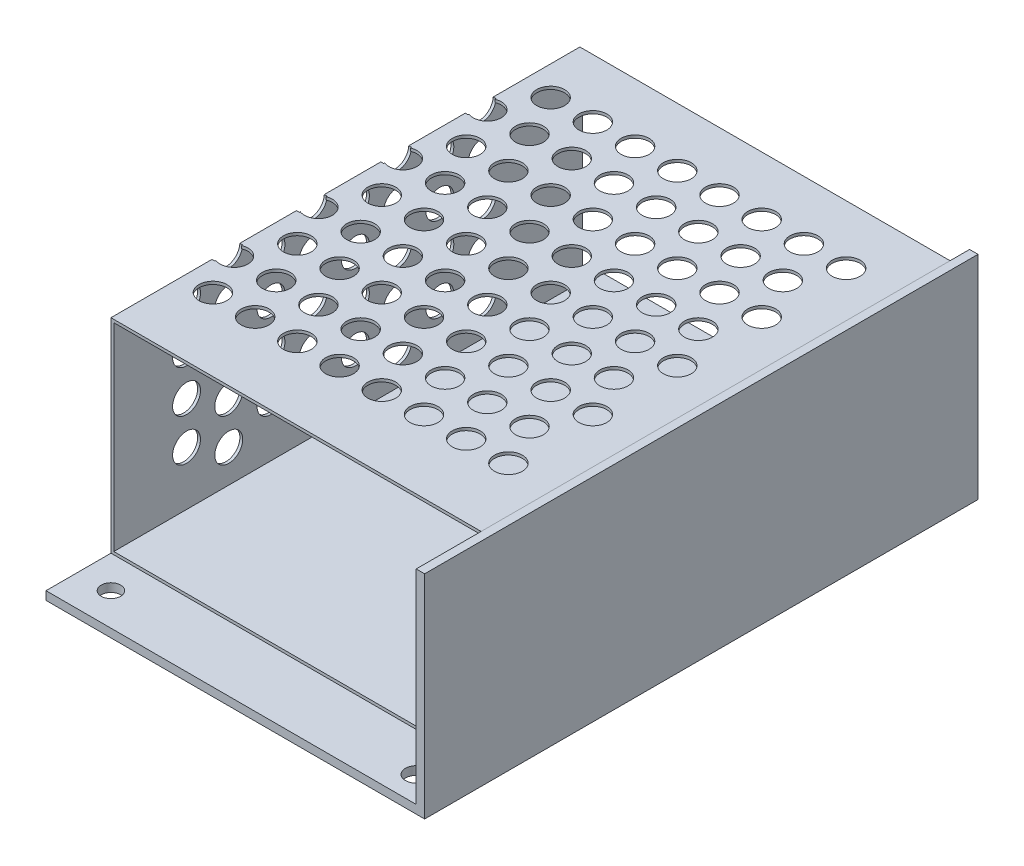
from build123d import *

# Parameters (mm, degrees)
SKETCH1_W           = 58.3
SKETCH1_H           = 85.2
BOSS_EXTRUDE1_DEPTH = 1.3
SKETCH2_W           = 1.3
SKETCH2_H           = 85.2
BOSS_EXTRUDE2_DEPTH = 31.4
CUT_EXTRUDE1_REACH  = 3.3
SKETCH3_R           = 1.5
SKETCH3_R_2         = 1.65
SKETCH4_W           = 57
SKETCH4_H           = 72.2
BOSS_EXTRUDE3_DEPTH = 31.4
SHELL1_T            = -0.44
SKETCH5_R           = 2.15
CUT_EXTRUDE2_DEPTH  = 0.44
SKETCH6_R           = 2.15
CUT_EXTRUDE3_DEPTH  = 0.44


with BuildPart() as part:
    # Sketch1 → Boss-Extrude1 (new body)
    with BuildSketch(Plane(origin=(0, 0, 0), x_dir=(1, 0, 0), z_dir=(0, 1, 0))):
        Rectangle(SKETCH1_W, SKETCH1_H)
    extrude(amount=BOSS_EXTRUDE1_DEPTH)

    # Sketch2 → Boss-Extrude2 (add)
    with BuildSketch(Plane(origin=(0, 1.3, 0), x_dir=(1, 0, 0), z_dir=(0, 1, 0))):
        with Locations((28.5, 0)):
            Rectangle(SKETCH2_W, SKETCH2_H)
    extrude(amount=BOSS_EXTRUDE2_DEPTH)

    # Sketch3 → Cut-Extrude1 (cut, up to next)
    with BuildSketch(Plane(origin=(0, 1.3, 0), x_dir=(1, 0, 0), z_dir=(0, 1, 0)), mode=Mode.PRIVATE) as cut_extrude1_sk1:
        with Locations((-24.15, -37.6)):
            Circle(SKETCH3_R)
    cut_extrude1_tool1 = extrude(cut_extrude1_sk1.sketch, amount=-CUT_EXTRUDE1_REACH, mode=Mode.PRIVATE) & part.part
    add(cut_extrude1_tool1.solids().sort_by_distance((-24.15, 1.3, 37.6))[0], mode=Mode.SUBTRACT)
    # Sketch3 → Cut-Extrude1 (cut, up to next)
    with BuildSketch(Plane(origin=(0, 1.3, 0), x_dir=(1, 0, 0), z_dir=(0, 1, 0)), mode=Mode.PRIVATE) as cut_extrude1_sk2:
        with Locations((-24.15, 29.4)):
            Circle(SKETCH3_R)
    cut_extrude1_tool2 = extrude(cut_extrude1_sk2.sketch, amount=-CUT_EXTRUDE1_REACH, mode=Mode.PRIVATE) & part.part
    add(cut_extrude1_tool2.solids().sort_by_distance((-24.15, 1.3, -29.4))[0], mode=Mode.SUBTRACT)
    # Sketch3 → Cut-Extrude1 (cut, up to next)
    with BuildSketch(Plane(origin=(0, 1.3, 0), x_dir=(1, 0, 0), z_dir=(0, 1, 0)), mode=Mode.PRIVATE) as cut_extrude1_sk3:
        with Locations((23.85, -38.6)):
            Circle(SKETCH3_R_2)
    cut_extrude1_tool3 = extrude(cut_extrude1_sk3.sketch, amount=-CUT_EXTRUDE1_REACH, mode=Mode.PRIVATE) & part.part
    add(cut_extrude1_tool3.solids().sort_by_distance((23.85, 1.3, 38.6))[0], mode=Mode.SUBTRACT)


with BuildPart() as body_2:
    # Sketch4 → Boss-Extrude3 (new body)
    with BuildSketch(Plane(origin=(0, 1.3, 0), x_dir=(1, 0, 0), z_dir=(0, 1, 0))):
        with Locations((-0.65, 3.5)):
            Rectangle(SKETCH4_W, SKETCH4_H)
    extrude(amount=BOSS_EXTRUDE3_DEPTH)

    # Shell1
    shell1_openings = [body_2.faces().sort_by_distance(p)[0] for p in [
        (-0.65, 17, 32.6),
        (-0.65, 17, -39.6),
    ]]
    offset(amount=SHELL1_T, openings=shell1_openings, kind=Kind.INTERSECTION)

    # Sketch5 → Cut-Extrude2 (cut)
    with BuildSketch(Plane(origin=(0, 32.7, 0), x_dir=(1, 0, 0), z_dir=(0, 1, 0))):
        with Locations((20.85, 30.6)):
            Circle(SKETCH5_R)
        with Locations((17.6, 24.1)):
            Circle(SKETCH5_R)
        with Locations((14.35, 30.6)):
            Circle(SKETCH5_R)
        with Locations((11.1, 24.1)):
            Circle(SKETCH5_R)
        with Locations((7.85, 30.6)):
            Circle(SKETCH5_R)
        with Locations((4.6, 24.1)):
            Circle(SKETCH5_R)
        with Locations((1.35, 30.6)):
            Circle(SKETCH5_R)
        with Locations((-1.9, 24.1)):
            Circle(SKETCH5_R)
        with Locations((-5.15, 30.6)):
            Circle(SKETCH5_R)
        with Locations((-8.4, 24.1)):
            Circle(SKETCH5_R)
        with Locations((-11.65, 30.6)):
            Circle(SKETCH5_R)
        with Locations((-14.9, 24.1)):
            Circle(SKETCH5_R)
        with Locations((-18.15, 30.6)):
            Circle(SKETCH5_R)
        with Locations((-21.4, 24.1)):
            Circle(SKETCH5_R)
        with Locations((-24.65, 30.6)):
            Circle(SKETCH5_R)
        with Locations((-27.9, 24.1)):
            Circle(SKETCH5_R)
        with Locations((20.85, 17.6)):
            Circle(SKETCH5_R)
        with Locations((17.6, 11.1)):
            Circle(SKETCH5_R)
        with Locations((14.35, 17.6)):
            Circle(SKETCH5_R)
        with Locations((11.1, 11.1)):
            Circle(SKETCH5_R)
        with Locations((7.85, 17.6)):
            Circle(SKETCH5_R)
        with Locations((4.6, 11.1)):
            Circle(SKETCH5_R)
        with Locations((1.35, 17.6)):
            Circle(SKETCH5_R)
        with Locations((-1.9, 11.1)):
            Circle(SKETCH5_R)
        with Locations((-5.15, 17.6)):
            Circle(SKETCH5_R)
        with Locations((-8.4, 11.1)):
            Circle(SKETCH5_R)
        with Locations((-11.65, 17.6)):
            Circle(SKETCH5_R)
        with Locations((-14.9, 11.1)):
            Circle(SKETCH5_R)
        with Locations((-18.15, 17.6)):
            Circle(SKETCH5_R)
        with Locations((-21.4, 11.1)):
            Circle(SKETCH5_R)
        with Locations((-24.65, 17.6)):
            Circle(SKETCH5_R)
        with Locations((-27.9, 11.1)):
            Circle(SKETCH5_R)
        with Locations((20.85, 4.6)):
            Circle(SKETCH5_R)
        with Locations((17.6, -1.9)):
            Circle(SKETCH5_R)
        with Locations((14.35, 4.6)):
            Circle(SKETCH5_R)
        with Locations((11.1, -1.9)):
            Circle(SKETCH5_R)
        with Locations((7.85, 4.6)):
            Circle(SKETCH5_R)
        with Locations((4.6, -1.9)):
            Circle(SKETCH5_R)
        with Locations((1.35, 4.6)):
            Circle(SKETCH5_R)
        with Locations((-1.9, -1.9)):
            Circle(SKETCH5_R)
        with Locations((-5.15, 4.6)):
            Circle(SKETCH5_R)
        with Locations((-8.4, -1.9)):
            Circle(SKETCH5_R)
        with Locations((-11.65, 4.6)):
            Circle(SKETCH5_R)
        with Locations((-14.9, -1.9)):
            Circle(SKETCH5_R)
        with Locations((-18.15, 4.6)):
            Circle(SKETCH5_R)
        with Locations((-21.4, -1.9)):
            Circle(SKETCH5_R)
        with Locations((-24.65, 4.6)):
            Circle(SKETCH5_R)
        with Locations((-27.9, -1.9)):
            Circle(SKETCH5_R)
        with Locations((20.85, -8.4)):
            Circle(SKETCH5_R)
        with Locations((17.6, -14.9)):
            Circle(SKETCH5_R)
        with Locations((14.35, -8.4)):
            Circle(SKETCH5_R)
        with Locations((11.1, -14.9)):
            Circle(SKETCH5_R)
        with Locations((7.85, -8.4)):
            Circle(SKETCH5_R)
        with Locations((4.6, -14.9)):
            Circle(SKETCH5_R)
        with Locations((1.35, -8.4)):
            Circle(SKETCH5_R)
        with Locations((-1.9, -14.9)):
            Circle(SKETCH5_R)
        with Locations((-5.15, -8.4)):
            Circle(SKETCH5_R)
        with Locations((-8.4, -14.9)):
            Circle(SKETCH5_R)
        with Locations((-11.65, -8.4)):
            Circle(SKETCH5_R)
        with Locations((-14.9, -14.9)):
            Circle(SKETCH5_R)
        with Locations((-18.15, -8.4)):
            Circle(SKETCH5_R)
        with Locations((-21.4, -14.9)):
            Circle(SKETCH5_R)
        with Locations((-24.65, -8.4)):
            Circle(SKETCH5_R)
        with Locations((-27.9, -14.9)):
            Circle(SKETCH5_R)
        with Locations((20.85, -21.4)):
            Circle(SKETCH5_R)
        with Locations((14.35, -21.4)):
            Circle(SKETCH5_R)
        with Locations((7.85, -21.4)):
            Circle(SKETCH5_R)
        with Locations((1.35, -21.4)):
            Circle(SKETCH5_R)
        with Locations((-5.15, -21.4)):
            Circle(SKETCH5_R)
        with Locations((-11.65, -21.4)):
            Circle(SKETCH5_R)
        with Locations((-18.15, -21.4)):
            Circle(SKETCH5_R)
        with Locations((-24.65, -21.4)):
            Circle(SKETCH5_R)
    extrude(amount=-CUT_EXTRUDE2_DEPTH, mode=Mode.SUBTRACT)

    # Sketch6 → Cut-Extrude3 (cut)
    with BuildSketch(Plane.ZY.offset(29.15)):
        with Locations((-24.1, 6.8)):
            Circle(SKETCH6_R)
        with Locations((-17.6, 10.05)):
            Circle(SKETCH6_R)
        with Locations((-11.1, 6.8)):
            Circle(SKETCH6_R)
        with Locations((-4.6, 10.05)):
            Circle(SKETCH6_R)
        with Locations((1.9, 6.8)):
            Circle(SKETCH6_R)
        with Locations((8.4, 10.05)):
            Circle(SKETCH6_R)
        with Locations((14.9, 6.8)):
            Circle(SKETCH6_R)
        with Locations((21.4, 10.05)):
            Circle(SKETCH6_R)
        with Locations((-11.1, 13.3)):
            Circle(SKETCH6_R)
        with Locations((-4.6, 16.55)):
            Circle(SKETCH6_R)
        with Locations((1.9, 13.3)):
            Circle(SKETCH6_R)
        with Locations((8.4, 16.55)):
            Circle(SKETCH6_R)
        with Locations((14.9, 13.3)):
            Circle(SKETCH6_R)
        with Locations((21.4, 16.55)):
            Circle(SKETCH6_R)
        with Locations((-11.1, 19.8)):
            Circle(SKETCH6_R)
        with Locations((-4.6, 23.05)):
            Circle(SKETCH6_R)
        with Locations((1.9, 19.8)):
            Circle(SKETCH6_R)
        with Locations((8.4, 23.05)):
            Circle(SKETCH6_R)
        with Locations((14.9, 19.8)):
            Circle(SKETCH6_R)
        with Locations((21.4, 23.05)):
            Circle(SKETCH6_R)
        with Locations((-11.1, 26.3)):
            Circle(SKETCH6_R)
        with Locations((-4.6, 29.55)):
            Circle(SKETCH6_R)
        with Locations((1.9, 26.3)):
            Circle(SKETCH6_R)
        with Locations((8.4, 29.55)):
            Circle(SKETCH6_R)
        with Locations((14.9, 26.3)):
            Circle(SKETCH6_R)
        with Locations((21.4, 29.55)):
            Circle(SKETCH6_R)
        with Locations((-11.1, 32.8)):
            Circle(SKETCH6_R)
        with Locations((-4.6, 36.05)):
            Circle(SKETCH6_R)
        with Locations((1.9, 32.8)):
            Circle(SKETCH6_R)
        with Locations((8.4, 36.05)):
            Circle(SKETCH6_R)
        with Locations((14.9, 32.8)):
            Circle(SKETCH6_R)
        with Locations((21.4, 36.05)):
            Circle(SKETCH6_R)
        with Locations((-24.1, 13.3)):
            Circle(SKETCH6_R)
        with Locations((-17.6, 16.55)):
            Circle(SKETCH6_R)
        with Locations((-24.1, 19.8)):
            Circle(SKETCH6_R)
        with Locations((-17.6, 23.05)):
            Circle(SKETCH6_R)
        with Locations((-24.1, 26.3)):
            Circle(SKETCH6_R)
        with Locations((-17.6, 29.55)):
            Circle(SKETCH6_R)
        with Locations((-24.1, 32.8)):
            Circle(SKETCH6_R)
        with Locations((-17.6, 36.05)):
            Circle(SKETCH6_R)
    extrude(amount=-CUT_EXTRUDE3_DEPTH, mode=Mode.SUBTRACT)


solid = Compound([part.part, body_2.part])
